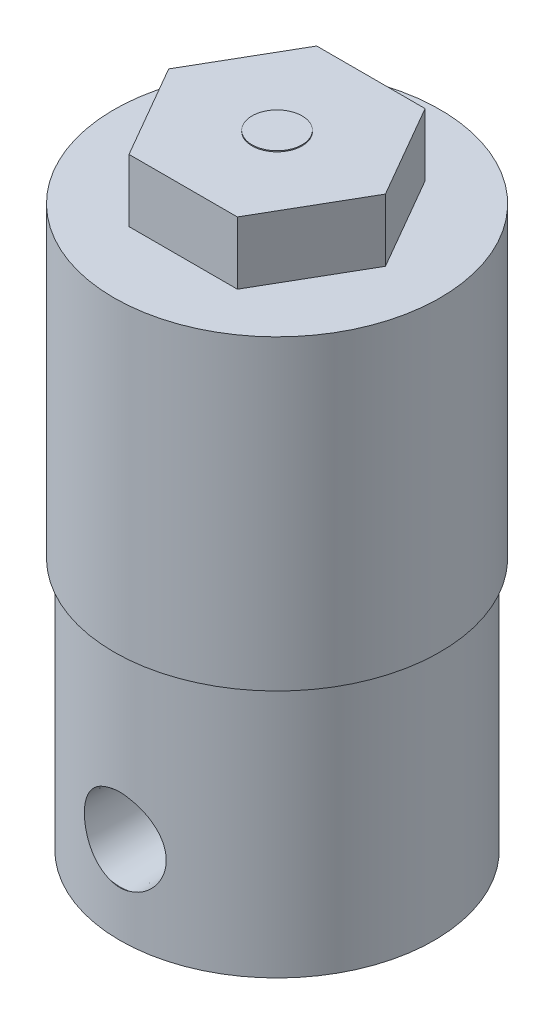
from build123d import *

# Parameters (mm, degrees)
ESQUISSE1_R               = 12.56
BOSS_EXTRU_1_DEPTH        = 20.19
ESQUISSE13_R              = 2
BOSS_EXTRU_2_DEPTH        = 29.59
ESQUISSE14_R              = 13.03
BOSS_EXTRU_3_DEPTH        = 24.51
BOSS_EXTRU_4_DEPTH        = 5
D_GAGEMENT_81_D           = 4.4958
D_GAGEMENT_81_DEPTH       = 8.649325414
D_GAGEMENT_81_CSINK_D     = 5.7658
D_GAGEMENT_81_CSINK_ANGLE = 90
D_GAGEMENT_81_TIP         = 1.350674586


with BuildPart() as part:
    # Esquisse1 → Boss.-Extru.1 (new body)
    with BuildSketch(Plane(origin=(0, 0, 0), x_dir=(1, 0, 0), z_dir=(0, 1, 0))):
        Circle(ESQUISSE1_R)
    extrude(amount=BOSS_EXTRU_1_DEPTH)

    # Esquisse9 → Trou taraudé 1/8 Rc1 (revolve, cut)
    with BuildSketch(Plane(origin=(0, 6.96, 12.56), x_dir=(0, -1, 0), z_dir=(1, 0, 0))):
        Polygon((0, 0), (0, 10.873399445), (3.95, 8.5), (3.95, 7.4), (3.05277742, 7.4), (3.283, 0.025), (3.308, 0), align=None)
    revolve(axis=Axis((0, 6.96, 18.91), (0, 0, -1)), mode=Mode.SUBTRACT)

    # Esquisse12 → Trou taraudé 1/8 Rc2 (revolve, cut)
    with BuildSketch(Plane(origin=(0, 6.949571946, -12.56), x_dir=(0, 1, 0), z_dir=(1, 0, 0))):
        Polygon((0, 0), (0, 10.873399445), (3.95, 8.5), (3.95, 7.4), (3.05277742, 7.4), (3.283, 0.025), (3.308, 0), align=None)
    revolve(axis=Axis((0, 6.949571946, -18.91), (0, 0, 1)), mode=Mode.SUBTRACT)

    # Esquisse13 → Boss.-Extru.2 (add)
    with BuildSketch(Plane(origin=(0, 20.19, 0), x_dir=(1, 0, 0), z_dir=(0, 1, 0))):
        Circle(ESQUISSE13_R)
    extrude(amount=BOSS_EXTRU_2_DEPTH)

    # Esquisse14 → Boss.-Extru.3 (add)
    with BuildSketch(Plane(origin=(0, 20.19, 0), x_dir=(1, 0, 0), z_dir=(0, 1, 0))):
        Circle(ESQUISSE14_R)
    extrude(amount=BOSS_EXTRU_3_DEPTH)

    # Esquisse16 → Boss.-Extru.4 (add)
    with BuildSketch(Plane(origin=(0, 44.7, 0), x_dir=(1, 0, 0), z_dir=(0, 1, 0))):
        Polygon((8.660254038, 0), (4.330127019, 7.5), (-4.330127019, 7.5), (-8.660254038, 0), (-4.330127019, -7.5), (4.330127019, -7.5), align=None)
    extrude(amount=BOSS_EXTRU_4_DEPTH)

    # Dégagement #81
    with Locations(Plane(origin=(-9.335, 0, 0), x_dir=(0, 0, -1), z_dir=(0, -1, 0))):
        with Locations((0, 0), (0, 18.67)):
            CounterSinkHole(D_GAGEMENT_81_D / 2, D_GAGEMENT_81_CSINK_D / 2, depth=D_GAGEMENT_81_DEPTH, counter_sink_angle=D_GAGEMENT_81_CSINK_ANGLE)
            with Locations((0, 0, -(D_GAGEMENT_81_DEPTH + D_GAGEMENT_81_TIP / 2))):  # 118° drill point
                Cone(0, D_GAGEMENT_81_D / 2, D_GAGEMENT_81_TIP, mode=Mode.SUBTRACT)


solid = part.part
